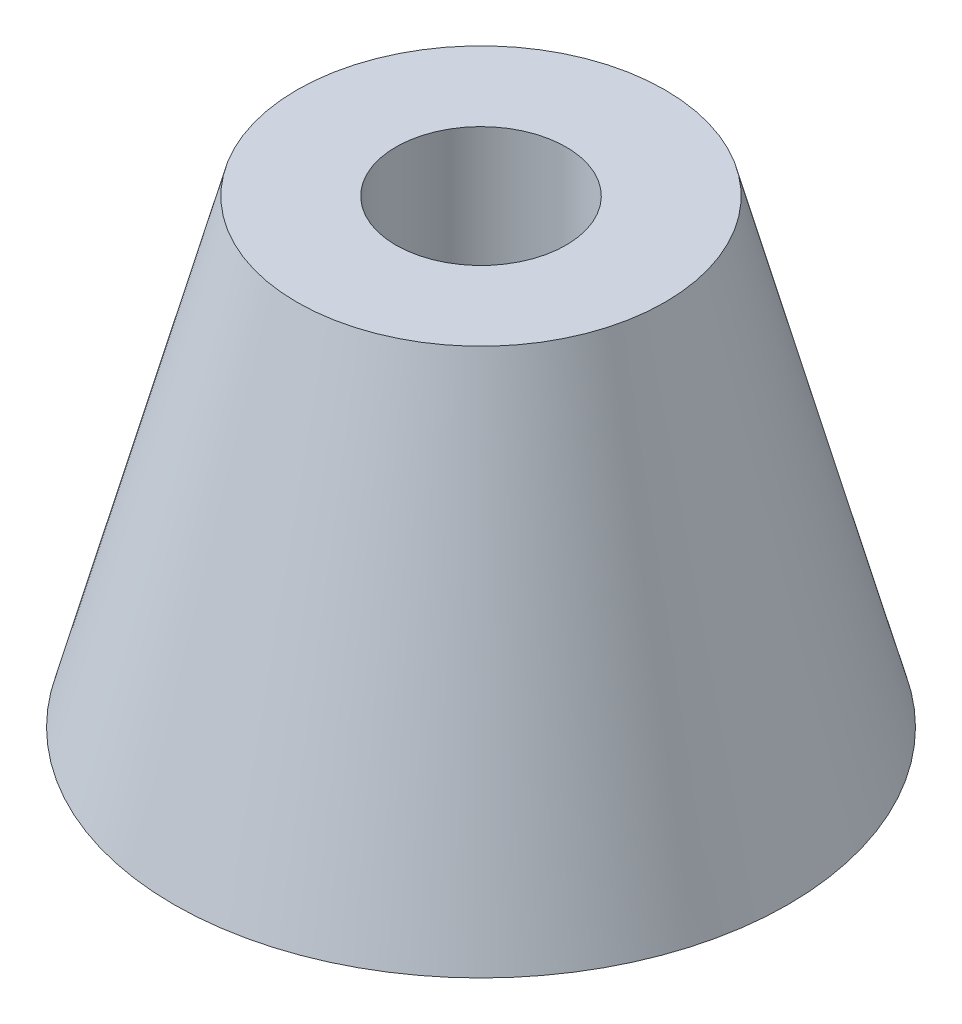
from build123d import *

# Parameters (mm, degrees)
SKETCH1_R           = 4
BOSS_EXTRUDE1_DEPTH = 10
BOSS_EXTRUDE1_TAPER = -15
SKETCH2_R           = 1.85
CUT_EXTRUDE1_DEPTH  = 11.0000001


with BuildPart() as part:
    # Sketch1 → Boss-Extrude1 (new body)
    with BuildSketch(Plane(origin=(0, 0, 0), x_dir=(1, 0, 0), z_dir=(0, 1, 0))):
        Circle(SKETCH1_R)
    extrude(amount=-BOSS_EXTRUDE1_DEPTH, taper=BOSS_EXTRUDE1_TAPER)

    # Sketch2 → Cut-Extrude1 (cut, through all)
    with BuildSketch(Plane(origin=(0, 0, 0), x_dir=(1, 0, 0), z_dir=(0, 1, 0))):
        Circle(SKETCH2_R)
    extrude(amount=-CUT_EXTRUDE1_DEPTH, mode=Mode.SUBTRACT)


solid = part.part
